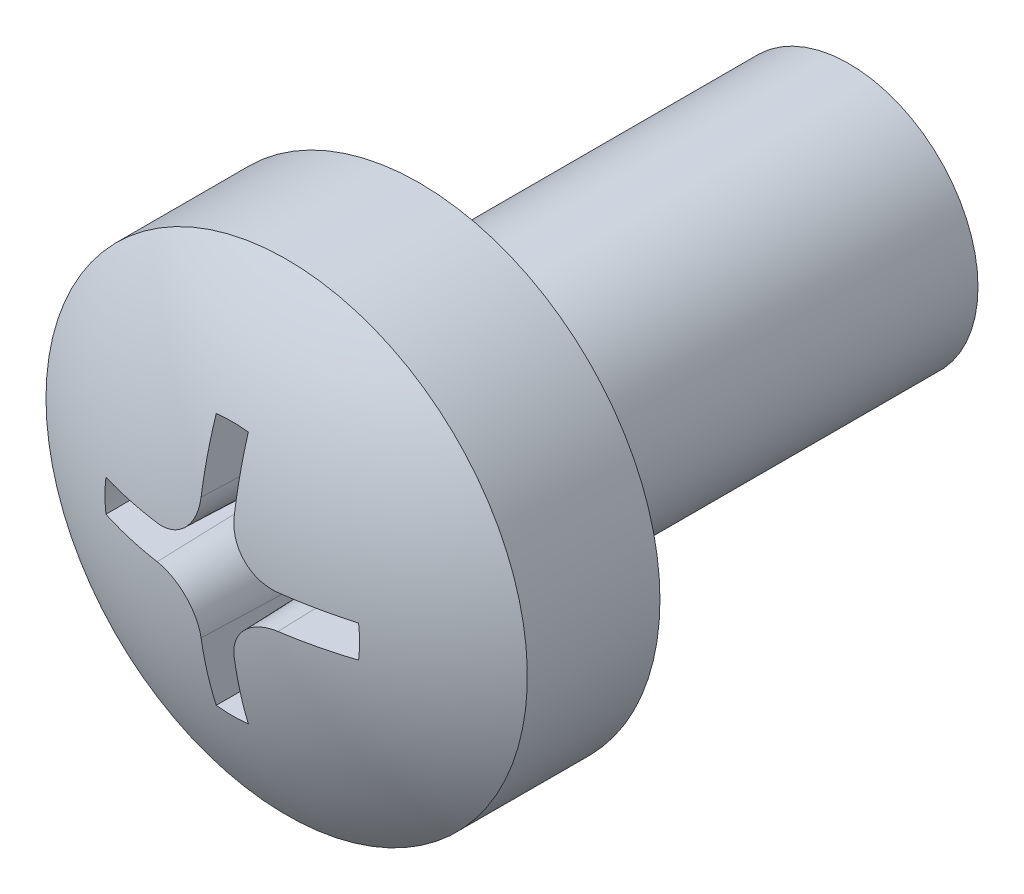
from build123d import *

# Parameters (mm, degrees)
SKETCH1_R               = 1.5
BASE_EXTRUDE_DEPTH      = 5
BASE_EXTRUDE_DEPTH_BACK = 0.0001
CUT_EXTRUDE1_DEPTH      = 1.799999969
CUT_EXTRUDE1_TAPER      = 2


with BuildPart() as part:
    # Sketch1 → Base-Extrude (new body, two sides)
    with BuildSketch(Plane.XY) as base_extrude_sk:
        Circle(SKETCH1_R)
    extrude(amount=BASE_EXTRUDE_DEPTH)
    extrude(base_extrude_sk.sketch, amount=-BASE_EXTRUDE_DEPTH_BACK)

    # Sketch6 → Boss-Revolve2 (revolve)
    with BuildSketch(Plane(origin=(0, 0, 0), x_dir=(1, 0, 0), z_dir=(0, 1, 0))):
        with BuildLine():
            Line((0, -5), (2.7999999, -5))
            Line((2.7999999, -5), (2.7999999, -6.54246308))
            ThreePointArc((2.7999999, -6.54246308), (1.46418655, -7.180811406), (0, -7.4))
            Line((0, -7.4), (0, -5))
        make_face()
    revolve(axis=Axis((0, 0, -0.393620135), (0, 0, 1)))

    # Sketch7 → Cut-Extrude1 (cut)
    with BuildSketch(Plane(origin=(0, 0, 7.7000001), x_dir=(-1, 0, 0), z_dir=(0, 0, -1))):
        with BuildLine():
            ThreePointArc((0.205000004, 1.48592565), (0, 1.500000013), (-0.205000004, 1.48592565))
            Line((-0.205000004, 1.48592565), (-0.205000004, 0.708178558))
            ThreePointArc((-0.205000004, 0.708178558), (-0.35072876, 0.355344481), (-0.702967546, 0.208182689))
            Line((-0.702967546, 0.208182689), (-1.48592565, 0.205000004))
            ThreePointArc((-1.48592565, 0.205000004), (-1.500000013, 0), (-1.48592565, -0.205000004))
            Line((-1.48592565, -0.205000004), (-0.702967546, -0.208182689))
            ThreePointArc((-0.702967546, -0.208182689), (-0.35072876, -0.355344481), (-0.205000004, -0.708178558))
            Line((-0.205000004, -0.708178558), (-0.205000004, -1.48592565))
            ThreePointArc((-0.205000004, -1.48592565), (0, -1.500000013), (0.205000004, -1.48592565))
            Line((0.205000004, -1.48592565), (0.205000004, -0.708178558))
            ThreePointArc((0.205000004, -0.708178558), (0.35072876, -0.355344481), (0.702967546, -0.208182689))
            Line((0.702967546, -0.208182689), (1.48592565, -0.205000004))
            ThreePointArc((1.48592565, -0.205000004), (1.500000013, 0), (1.48592565, 0.205000004))
            Line((1.48592565, 0.205000004), (0.702967546, 0.208182689))
            ThreePointArc((0.702967546, 0.208182689), (0.35072876, 0.355344481), (0.205000004, 0.708178558))
            Line((0.205000004, 0.708178558), (0.205000004, 1.48592565))
        make_face()
    extrude(amount=CUT_EXTRUDE1_DEPTH, taper=CUT_EXTRUDE1_TAPER, mode=Mode.SUBTRACT)


solid = part.part
